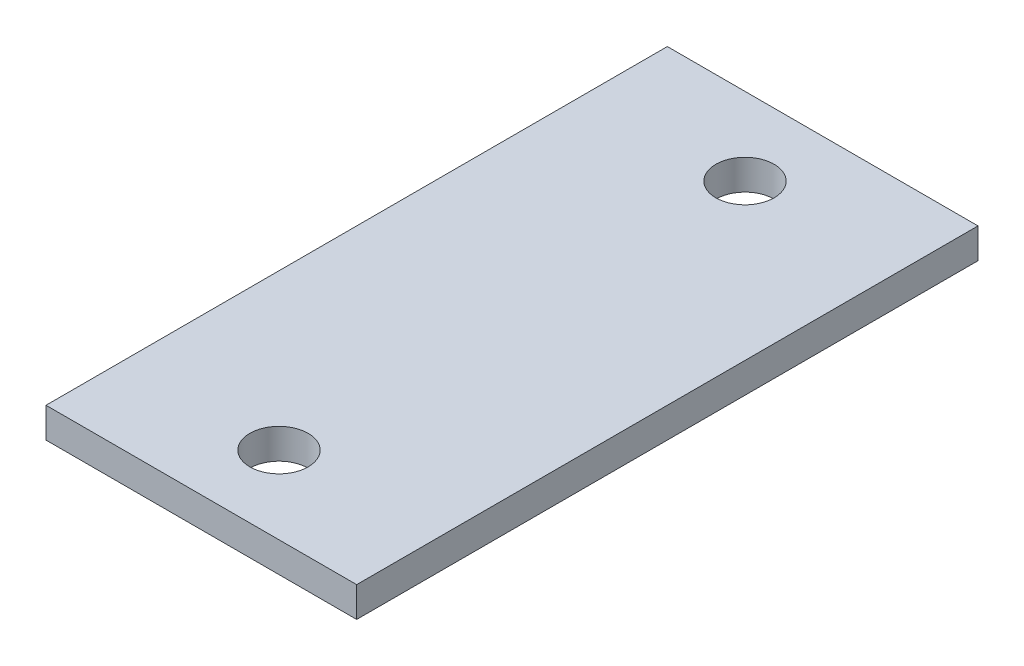
from build123d import *

# Parameters (mm, degrees)
SKETCH1_W    = 50.8
SKETCH1_H    = 101.6
SKETCH1_R    = 4.7625
HAMMER_DEPTH = 4.93522


with BuildPart() as part:
    # Sketch1 → Hammer (new body)
    with BuildSketch(Plane(origin=(0, 0, 0), x_dir=(1, 0, 0), z_dir=(0, 1, 0))):
        with Locations((25.4, 50.8)):
            Rectangle(SKETCH1_W, SKETCH1_H)
        with Locations((25.4, 12.7)):
            Circle(SKETCH1_R, mode=Mode.SUBTRACT)
        with Locations((25.4, 88.9)):
            Circle(SKETCH1_R, mode=Mode.SUBTRACT)
    extrude(amount=HAMMER_DEPTH)


solid = part.part
